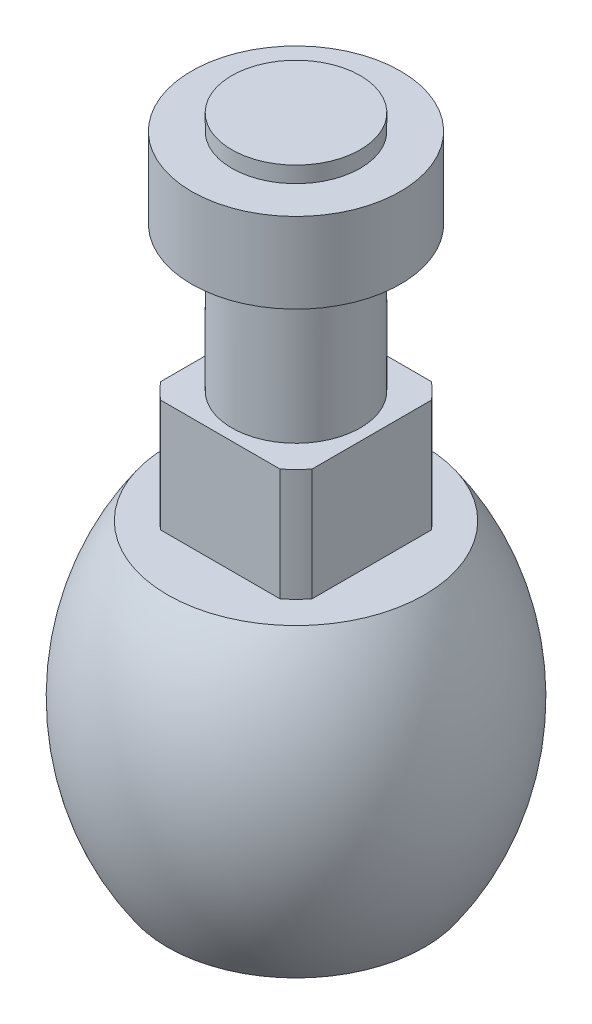
from build123d import *

# Parameters (mm, degrees)
CUT_EXTRUDE1_DEPTH  = 7
SKETCH3_R           = 5
BOSS_EXTRUDE1_DEPTH = 1
SKETCH4_R           = 6.5
BOSS_EXTRUDE2_DEPTH = 5


with BuildPart() as part:
    # Sketch1 → Revolve1 (revolve)
    with BuildSketch(Plane.XY):
        with BuildLine():
            Line((-8, 0), (0, 0))
            Line((0, 0), (0, 41))
            Line((0, 41), (-4, 41))
            Line((-4, 41), (-4, 26))
            Line((-4, 26), (-6, 26))
            Line((-6, 26), (-6, 19))
            Line((-6, 19), (-8, 19))
            ThreePointArc((-8, 19), (-11, 9.5), (-8, 0))
        make_face()
    revolve(axis=Axis((0, 0, 0), (0, 1, 0)))

    # Sketch2 → Cut-Extrude1 (cut)
    with BuildSketch(Plane(origin=(0, 26, 0), x_dir=(1, 0, 0), z_dir=(0, 1, 0))):
        with BuildLine():
            Line((-3.713074887, 4.713074887), (3.713074887, 4.713074887))
            ThreePointArc((3.713074887, 4.713074887), (0, 6), (-3.713074887, 4.713074887))
        make_face()
        with BuildLine():
            Line((4.713074887, 3.713074887), (4.713074887, -3.713074887))
            ThreePointArc((4.713074887, -3.713074887), (6, 0), (4.713074887, 3.713074887))
        make_face()
        with BuildLine():
            Line((3.713074887, -4.713074887), (-3.713074887, -4.713074887))
            ThreePointArc((-3.713074887, -4.713074887), (0, -6), (3.713074887, -4.713074887))
        make_face()
        with BuildLine():
            Line((-4.713074887, -3.713074887), (-4.713074887, 3.713074887))
            ThreePointArc((-4.713074887, 3.713074887), (-6, 0), (-4.713074887, -3.713074887))
        make_face()
    extrude(amount=-CUT_EXTRUDE1_DEPTH, mode=Mode.SUBTRACT)

    # Sketch3 → Boss-Extrude1 (add)
    with BuildSketch(Plane.XZ):
        Circle(SKETCH3_R)
    extrude(amount=BOSS_EXTRUDE1_DEPTH)

    # Sketch4 → Boss-Extrude2 (add)
    with BuildSketch(Plane(origin=(0, 40, 0), x_dir=(1, 0, 0), z_dir=(0, 1, 0))):
        Circle(SKETCH4_R)
    extrude(amount=-BOSS_EXTRUDE2_DEPTH)


solid = part.part
